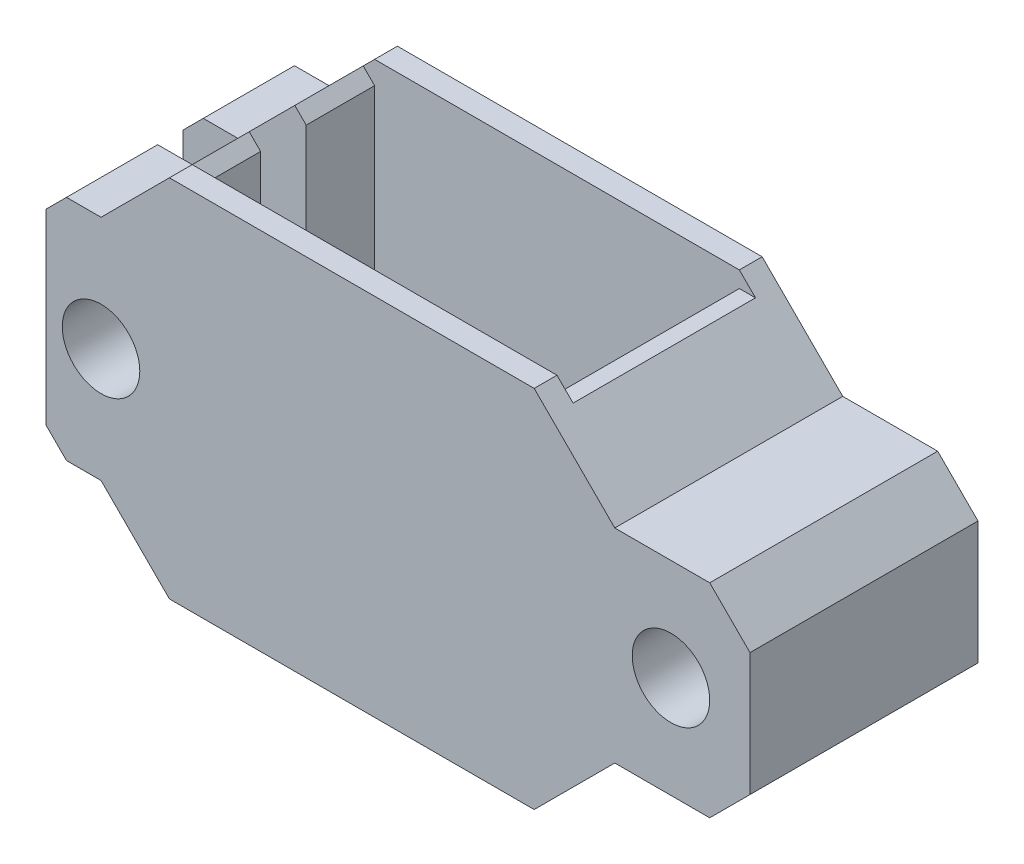
from build123d import *

# Parameters (mm, degrees)
SKETCH1_R             = 1.7
SKETCH1_R_2           = 1.25
BOSS_EXTRUDE1_DEPTH   = 5
SKETCH11_W            = 16
SKETCH11_H            = 16
CUT_EXTRUDE6_DEPTH    = 4
SKETCH13_W            = 7.423787947
SKETCH13_H            = 16.529940363
CUT_EXTRUDE8_DEPTH    = 1
CHAMFER2_SIZE2        = 1
CHAMFER2_SIZE         = 0.707106781
CHAMFER2_EDGE_2_SIZE2 = 1
CHAMFER2_EDGE_2_SIZE  = 0.707106781
CHAMFER2_EDGE_3_SIZE2 = 1
CHAMFER2_EDGE_3_SIZE  = 0.707106781
CHAMFER2_EDGE_4_SIZE2 = 0.707106781
CHAMFER2_EDGE_4_SIZE  = 1
SKETCH15_R            = 1.7
CUT_EXTRUDE9_DEPTH    = 5


with BuildPart() as part:
    # Sketch1 → Boss-Extrude1 (new body)
    with BuildSketch(Plane.XY):
        Polygon((0, -8), (-16, -8), (-19, -5), (-20.515302869, -5), (-21.413786532, -4.101516338), (-21.413786532, -1.535700598), (-21.413786532, 4.101516338), (-20.515302869, 5), (-19, 5), (-16, 8), (0, 8), (3.535533906, 4.464466094), (6, 4.464466094), (7.7, 4.464466094), (9.467766953, 2.696699141), (9.467766953, -2.696699141), (7.7, -4.464466094), (6, -4.464466094), (3.535533906, -4.464466094), align=None)
        with Locations((6, 0)):
            Circle(SKETCH1_R, mode=Mode.SUBTRACT)
        with Locations((-19, 0)):
            Circle(SKETCH1_R_2, mode=Mode.SUBTRACT)
    extrude(amount=BOSS_EXTRUDE1_DEPTH)

    # Sketch11 → Cut-Extrude6 (cut)
    with BuildSketch(Plane.XY.offset(5)):
        with Locations((-8, 0)):
            Rectangle(SKETCH11_W, SKETCH11_H)
    extrude(amount=-CUT_EXTRUDE6_DEPTH, mode=Mode.SUBTRACT)

    # Sketch13 → Cut-Extrude8 (cut)
    with BuildSketch(Plane.XY.offset(5)):
        with Locations((-19.711893974, -0.264970181)):
            Rectangle(SKETCH13_W, SKETCH13_H)
    extrude(amount=-CUT_EXTRUDE8_DEPTH, mode=Mode.SUBTRACT)

    # Chamfer2
    chamfer2_edges = [part.edges().sort_by_distance(p)[0] for p in [
        (0, -8, 3),
    ]]
    chamfer(chamfer2_edges, length=CHAMFER2_SIZE, length2=CHAMFER2_SIZE2)

    # Chamfer2 edge 2
    chamfer2_edge_2_edges = [part.edges().sort_by_distance(p)[0] for p in [
        (0, 8, 3),
    ]]
    chamfer(chamfer2_edge_2_edges, length=CHAMFER2_EDGE_2_SIZE, length2=CHAMFER2_EDGE_2_SIZE2)

    # Chamfer2 edge 3
    chamfer2_edge_3_edges = [part.edges().sort_by_distance(p)[0] for p in [
        (-16, -8, 2.5),
    ]]
    chamfer(chamfer2_edge_3_edges, length=CHAMFER2_EDGE_3_SIZE, length2=CHAMFER2_EDGE_3_SIZE2)

    # Chamfer2 edge 4
    chamfer2_edge_4_edges = [part.edges().sort_by_distance(p)[0] for p in [
        (-16, 8, 2.5),
    ]]
    chamfer(chamfer2_edge_4_edges, length=CHAMFER2_EDGE_4_SIZE, length2=CHAMFER2_EDGE_4_SIZE2)

    # Mirror1: part across plane


with BuildPart() as part_1:
    add(part.part)
    add(part.part.mirror(Plane(origin=(0, 0, 5), x_dir=(1, 0, 0), z_dir=(0, 0, -1))))

    # Sketch15 → Cut-Extrude9 (cut)
    with BuildSketch(Plane.XY.offset(10)):
        with Locations((-19, 0)):
            Circle(SKETCH15_R)
    extrude(amount=-CUT_EXTRUDE9_DEPTH, mode=Mode.SUBTRACT)


solid = part_1.part
